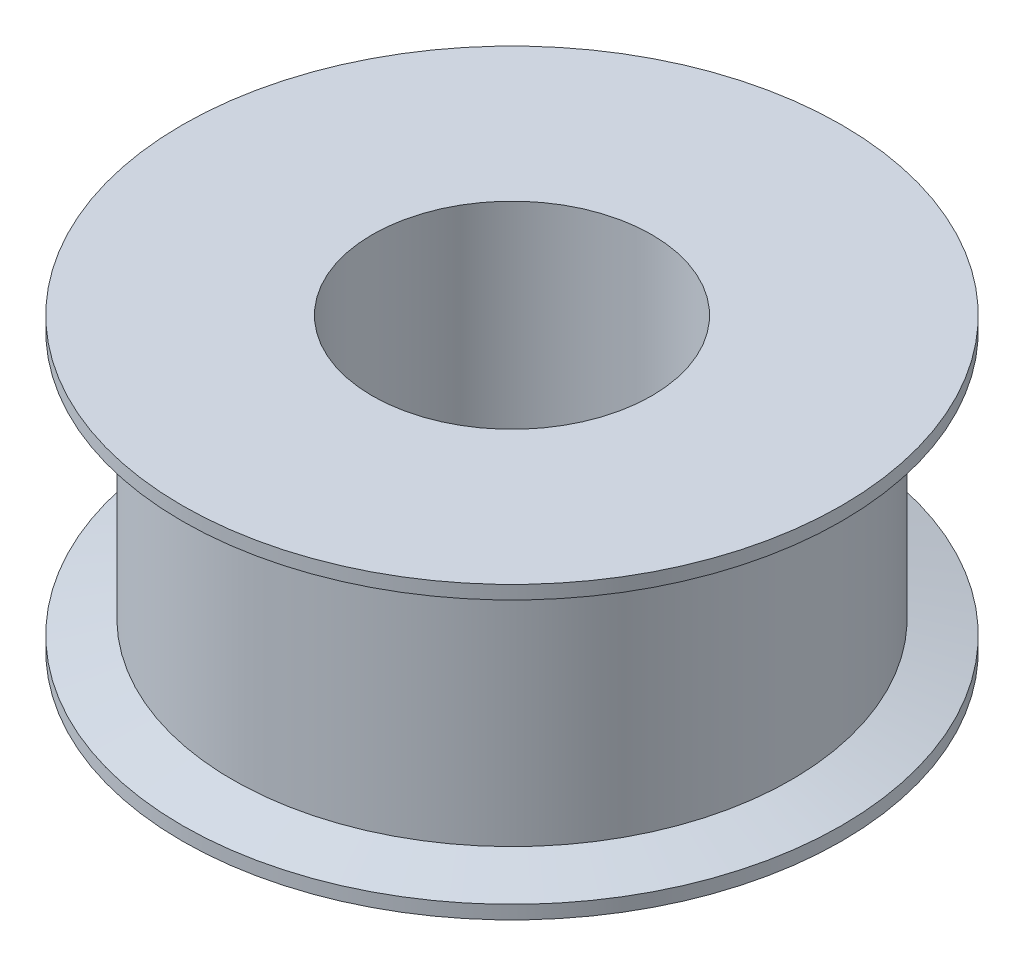
from build123d import *


with BuildPart() as part:
    # Sketch1 → Revolve1 (revolve)
    with BuildSketch(Plane.XY):
        Polygon((6.35127, 0), (6.35127, 13.208), (14.986, 13.208), (14.986, 12.593499952), (12.7, 11.938), (12.7, 1.27), (14.986, 0.614500048), (14.986, 0), align=None)
    revolve(axis=Axis((0, 0, 0), (0, 1, 0)))


solid = part.part
